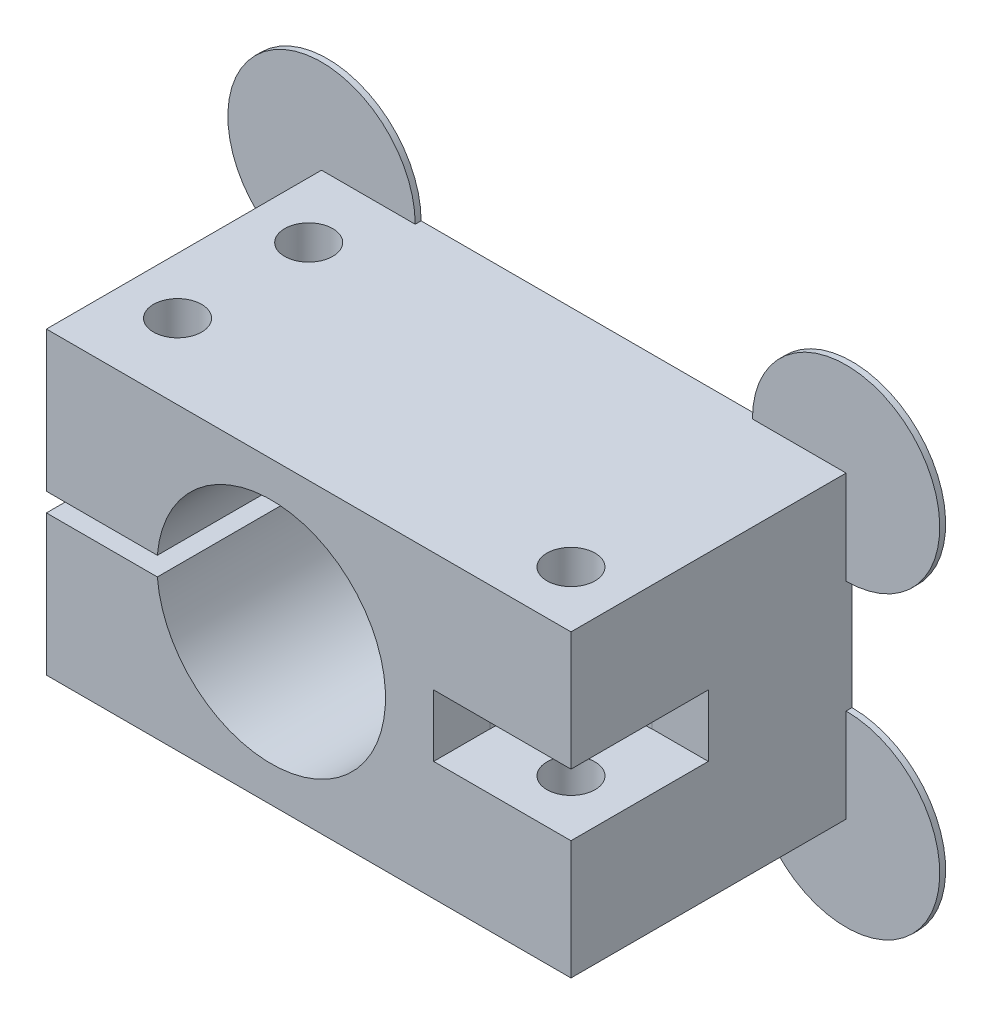
from build123d import *

# Parameters (mm, degrees)
SKETCH1_W             = 35.56
SKETCH1_H             = 20.32
BOSS_EXTRUDE1_DEPTH   = 19.05
SKETCH2_R             = 7.747
CUT_EXTRUDE1_DEPTH    = 20.05
SKETCH3_W             = 7.5451369
SKETCH3_H             = 1.27
CUT_EXTRUDE2_DEPTH    = 20.05
CUT_EXTRUDE4_DEPTH    = 2.1
F_4_CLEARANCE_HOLE1_D = 3.2639
SKETCH12_R            = 6.35
BOSS_EXTRUDE2_DEPTH   = 0.4


with BuildPart() as part:
    # Sketch1 → Boss-Extrude1 (new body)
    with BuildSketch(Plane.XY):
        with Locations((2.54, 0)):
            Rectangle(SKETCH1_W, SKETCH1_H)
    extrude(amount=BOSS_EXTRUDE1_DEPTH)

    # Sketch2 → Cut-Extrude1 (cut, through all)
    with BuildSketch(Plane.XY.offset(19.05)):
        Circle(SKETCH2_R)
    extrude(amount=-CUT_EXTRUDE1_DEPTH, mode=Mode.SUBTRACT)

    # Sketch3 → Cut-Extrude2 (cut, through all)
    with BuildSketch(Plane.XY.offset(19.05)):
        with Locations((-11.4935, 0)):
            Rectangle(SKETCH3_W, SKETCH3_H)
    extrude(amount=-CUT_EXTRUDE2_DEPTH, mode=Mode.SUBTRACT)

    # Sketch9 → Cut-Extrude4 (cut, symmetric)
    with BuildSketch(Plane(origin=(0, 0, 0), x_dir=(1, 0, 0), z_dir=(0, 1, 0))):
        with BuildLine():
            Line((11.01, -15.24), (11.01, -20.74))
            Line((11.01, -20.74), (22.01, -20.74))
            Line((22.01, -20.74), (22.01, -9.74))
            Line((22.01, -9.74), (16.51, -9.74))
            ThreePointArc((16.51, -9.74), (12.620912703, -11.350912703), (11.01, -15.24))
        make_face()
    extrude(amount=CUT_EXTRUDE4_DEPTH, both=True, mode=Mode.SUBTRACT)

    # #4 Clearance Hole1 (through all)
    with Locations(Plane(origin=(0, -10.16, 0), x_dir=(-1, 0, 0), z_dir=(0, -1, 0))):
        with Locations((11.43, -13.97), (11.43, -5.08), (-16.51, -15.24)):
            Hole(F_4_CLEARANCE_HOLE1_D / 2)

    # Sketch12 → Boss-Extrude2 (add)
    with BuildSketch(Plane(origin=(0, 0, 0), x_dir=(-1, 0, 0), z_dir=(0, 0, -1))):
        with Locations((15.24, -10.16)):
            Circle(SKETCH12_R)
        with Locations((-20.32, -10.16)):
            Circle(SKETCH12_R)
        with Locations((-20.32, 10.16)):
            Circle(SKETCH12_R)
        with Locations((15.24, 10.16)):
            Circle(SKETCH12_R)
    extrude(amount=-BOSS_EXTRUDE2_DEPTH)


solid = part.part
